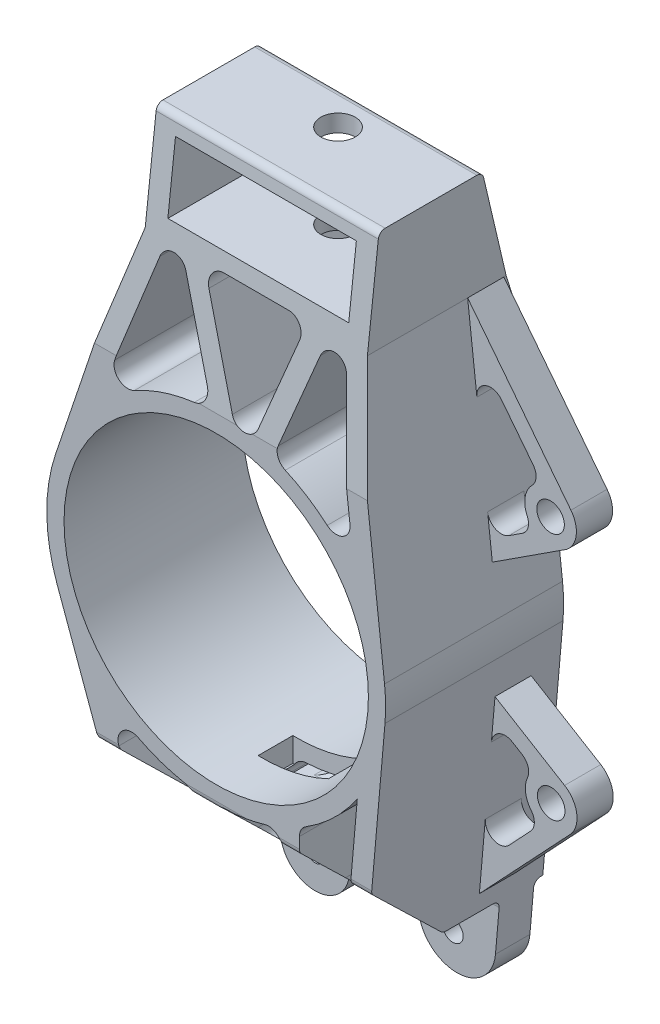
from build123d import *

# Parameters (mm, degrees)
SKETCH1_R               = 3
SKETCH1_R_2             = 44.17744667
SKETCH1_W               = 52.5
SKETCH1_H               = 19.5
BOSS_EXTRUDE1_DEPTH     = 25.835
CUT_EXTRUDE1_DEPTH      = 125.461402053
CUT_EXTRUDE1_DEPTH_BACK = 125.461402053
FILLET1_R               = 2
SKETCH5_R               = 4
BOSS_EXTRUDE2_DEPTH     = 10.5
BOSS_EXTRUDE3_DEPTH     = 26.37
CUT_EXTRUDE2_REACH      = 175.948
CUT_EXTRUDE2_END_RADIUS = 49.17744667
SKETCH7_R               = 2.75
CUT_EXTRUDE4_REACH      = 222.707
SKETCH10_R              = 5
CUT_EXTRUDE5_START      = -32.848332
CUT_EXTRUDE5_DEPTH      = 61.004944
SKETCH12_W              = 20.384350052
SKETCH12_H              = 10.085001151
CUT_EXTRUDE6_DEPTH      = 51.17744667


with BuildPart() as part:
    # Sketch1 → Boss-Extrude1 (new, symmetric)
    with BuildSketch(Plane.XY):
        with BuildLine():
            Line((-24.333061453, 81.876712624), (-46.608830439, 15.685604423))
            ThreePointArc((-46.608830439, 15.685604423), (-49.173776541, -0.600800907), (-46.211683745, -16.819677359))
            Line((-46.211683745, -16.819677359), (-19.916030232, -89.066391616))
            ThreePointArc((-19.916030232, -89.066391616), (-8.753130377, -95.528899343), (-0.427073715, -85.67744667))
            Line((-0.427073715, -85.67744667), (-0.427073715, -71.17744667))
            Line((-0.427073715, -71.17744667), (19.572926285, -71.17744667))
            Line((19.572926285, -71.17744667), (19.572926285, -85.67744667))
            ThreePointArc((19.572926285, -85.67744667), (30.838296467, -95.676822157), (41.890099306, -85.441895218))
            Line((41.890099306, -85.441895218), (48.990311639, -4.286096891))
            ThreePointArc((48.990311639, -4.286096891), (49.173233519, 0.643712888), (48.861326946, 5.567045008))
            Line((48.861326946, 5.567045008), (40.166938547, 81.876712624))
            Line((40.166938547, 81.876712624), (40.166938547, 111.376712624))
            Line((40.166938547, 111.376712624), (-24.333061453, 111.376712624))
            Line((-24.333061453, 111.376712624), (-24.333061453, 81.876712624))
        make_face()
        with Locations((-10.474465133, -85.629942955)):
            Circle(SKETCH1_R, mode=Mode.SUBTRACT)
        with Locations((29.525534867, -85.629942955)):
            Circle(SKETCH1_R, mode=Mode.SUBTRACT)
        Circle(SKETCH1_R_2, mode=Mode.SUBTRACT)
        with BuildLine():
            Line((-1.489783191, 81.876712624), (17.323660285, 81.876712624))
            ThreePointArc((17.323660285, 81.876712624), (20.595092, 80.178393429), (21.088556078, 76.525579889))
            Line((21.088556078, 76.525579889), (11.974377491, 51.129161219))
            ThreePointArc((11.974377491, 51.129161219), (8.249997752, 48.480499153), (4.472728318, 51.053173015))
            Line((4.472728318, 51.053173015), (-5.226536572, 76.449591685))
            ThreePointArc((-5.226536572, 76.449591685), (-4.784360839, 80.145138977), (-1.489783191, 81.876712624))
        make_face(mode=Mode.SUBTRACT)
        with Locations((7.916938547, 96.626712624)):
            Rectangle(SKETCH1_W, SKETCH1_H, mode=Mode.SUBTRACT)
        with BuildLine():
            Line((34.927451287, 74.861073276), (38.829349223, 40.614554616))
            ThreePointArc((38.829349223, 40.614554616), (36.718951762, 36.62254493), (32.233268993, 37.140781239))
            ThreePointArc((32.233268993, 37.140781239), (26.426414079, 41.473677194), (20.045955076, 44.906357524))
            ThreePointArc((20.045955076, 44.906357524), (17.997201864, 46.989529636), (17.911559151, 49.91008799))
            Line((17.911559151, 49.91008799), (27.188268072, 75.759393156))
            ThreePointArc((27.188268072, 75.759393156), (31.414364326, 78.381583228), (34.927451287, 74.861073276))
        make_face(mode=Mode.SUBTRACT)
        with BuildLine():
            Line((-12.022760406, 77.427653422), (-3.135959437, 54.158578845))
            ThreePointArc((-3.135959437, 54.158578845), (-3.438154868, 50.681138006), (-6.355748333, 48.765005118))
            ThreePointArc((-6.355748333, 48.765005118), (-15.310652659, 46.733341162), (-23.731752898, 43.07232482))
            ThreePointArc((-23.731752898, 43.07232482), (-28.226410266, 43.50588442), (-29.453122193, 47.851583055))
            Line((-29.453122193, 47.851583055), (-19.550587426, 77.27636972))
            ThreePointArc((-19.550587426, 77.27636972), (-15.839883944, 79.999724981), (-12.022760406, 77.427653422))
        make_face(mode=Mode.SUBTRACT)
        with BuildLine():
            Line((-28.275211733, -48.556902797), (-22.819798581, -63.545527244))
            ThreePointArc((-22.819798581, -63.545527244), (-21.355333844, -65.454054848), (-19.061028098, -66.17744667))
            Line((-19.061028098, -66.17744667), (-10.227738023, -66.17744667))
            ThreePointArc((-10.227738023, -66.17744667), (-7.399310898, -65.005873795), (-6.227738023, -62.17744667))
            Line((-6.227738023, -62.17744667), (-6.227738023, -52.184616596))
            ThreePointArc((-6.227738023, -52.184616596), (-7.139266231, -49.642699605), (-9.458409019, -48.259297134))
            ThreePointArc((-9.458409019, -48.259297134), (-16.230589371, -46.421861549), (-22.672318014, -43.639285705))
            ThreePointArc((-22.672318014, -43.639285705), (-27.155040875, -44.182530153), (-28.275211733, -48.556902797))
        make_face(mode=Mode.SUBTRACT)
        with BuildLine():
            Line((24.156612029, -45.111484496), (24.156612029, -62.17744667))
            ThreePointArc((24.156612029, -62.17744667), (25.328184905, -65.005873795), (28.156612029, -66.17744667))
            Line((28.156612029, -66.17744667), (37.552601137, -66.17744667))
            Line((37.552601137, -66.17744667), (40.961501413, -27.213538231))
            ThreePointArc((40.961501413, -27.213538231), (34.276118097, -35.264273553), (26.038675664, -41.718205027))
            ThreePointArc((26.038675664, -41.718205027), (24.658630793, -43.171348606), (24.156612029, -45.111484496))
        make_face(mode=Mode.SUBTRACT)
        with BuildLine():
            Line((-1.227738023, -53.105135325), (-1.227738023, -62.17744667))
            ThreePointArc((-1.227738023, -62.17744667), (-0.056165148, -65.005873795), (2.772261977, -66.17744667))
            Line((2.772261977, -66.17744667), (15.156612029, -66.17744667))
            ThreePointArc((15.156612029, -66.17744667), (17.985039154, -65.005873795), (19.156612029, -62.17744667))
            Line((19.156612029, -62.17744667), (19.156612029, -50.971736739))
            ThreePointArc((19.156612029, -50.971736739), (17.548231477, -47.765468438), (14.016533821, -47.137649927))
            ThreePointArc((14.016533821, -47.137649927), (8.348617755, -48.463613594), (2.563732824, -49.110574574))
            ThreePointArc((2.563732824, -49.110574574), (-0.128954717, -50.351421162), (-1.227738023, -53.105135325))
        make_face(mode=Mode.SUBTRACT)
    extrude(amount=BOSS_EXTRUDE1_DEPTH, both=True)

    # Sketch3 → Cut-Extrude1 (cut, two sides)
    with BuildSketch(Plane(origin=(0, 0, 0), x_dir=(0, 0, -1), z_dir=(1, 0, 0))) as cut_extrude1_sk:
        with BuildLine():
            Line((25.835, -95.67744667), (25.835, -71.17744667))
            Line((25.835, -71.17744667), (25.335, -71.17744667))
            ThreePointArc((25.335, -71.17744667), (23.920786438, -71.763233108), (23.335, -73.17744667))
            Line((23.335, -73.17744667), (23.335, -95.67744667))
            Line((23.335, -95.67744667), (25.835, -95.67744667))
        make_face()
        with BuildLine():
            Line((13.335, -95.67744667), (13.335, -73.17744667))
            ThreePointArc((13.335, -73.17744667), (12.749213562, -71.763233108), (11.335, -71.17744667))
            Line((11.335, -71.17744667), (-2.354089758, -71.17744667))
            ThreePointArc((-2.354089758, -71.17744667), (-3.105579113, -71.030893122), (-3.746935037, -70.612710419))
            Line((-3.746935037, -70.612710419), (-25.835, -49.17744667))
            Line((-25.835, -49.17744667), (-25.835, -95.67744667))
            Line((-25.835, -95.67744667), (13.335, -95.67744667))
        make_face()
        with BuildLine():
            Line((-25.835, 49.17744667), (-18.95036426, 109.603119051))
            ThreePointArc((-18.95036426, 109.603119051), (-18.294983881, 110.868827374), (-16.963220549, 111.376712624))
            Line((-16.963220549, 111.376712624), (-25.835, 111.376712624))
            Line((-25.835, 111.376712624), (-25.835, 49.17744667))
        make_face()
        with BuildLine():
            Line((11.613591816, 109.833253612), (25.835, 49.17744667))
            Line((25.835, 49.17744667), (25.835, 111.376712624))
            Line((25.835, 111.376712624), (9.666396313, 111.376712624))
            ThreePointArc((9.666396313, 111.376712624), (10.908756571, 110.944048258), (11.613591816, 109.833253612))
        make_face()
    extrude(amount=CUT_EXTRUDE1_DEPTH, mode=Mode.SUBTRACT)
    extrude(cut_extrude1_sk.sketch, amount=-CUT_EXTRUDE1_DEPTH_BACK, mode=Mode.SUBTRACT)

    # Fillet1
    fillet1_edges = [part.edges().sort_by_distance(p)[0] for p in [
        (-31.241885551, -49.17744667, 25.835),
        (-2.787508752, -49.17744667, 25.835),
        (21.444104907, -49.17744667, 25.835),
        (42.05136793, -49.17744667, 25.835),
    ]]
    fillet(fillet1_edges, radius=FILLET1_R)

    # Sketch5 → Boss-Extrude2 (add)
    with BuildSketch(Plane.XY.offset(-6.985)):
        with BuildLine():
            Line((40.166938547, 81.876712624), (70.147675928, 43.503118685))
            ThreePointArc((70.147675928, 43.503118685), (71.694607282, 38.083802311), (69.030880587, 33.117259582))
            Line((69.030880587, 33.117259582), (47.32817385, 19.023357034))
            Line((47.32817385, 19.023357034), (45.963969857, 30.996821812))
            ThreePointArc((45.963969857, 30.996821812), (48.23198232, 27.831814086), (52.116813419, 28.094952396))
            Line((52.116813419, 28.094952396), (56.014564965, 30.626181846))
            ThreePointArc((56.014564965, 30.626181846), (57.683412554, 32.886567746), (57.453951939, 35.686879249))
            ThreePointArc((57.453951939, 35.686879249), (56.843274314, 40.140256162), (58.888701598, 44.142970281))
            ThreePointArc((58.888701598, 44.142970281), (60.029514526, 46.719915118), (59.188001317, 49.409516268))
            Line((59.188001317, 49.409516268), (49.982109578, 61.192520367))
            ThreePointArc((49.982109578, 61.192520367), (45.315472094, 62.432036481), (42.855779141, 58.27706161))
            Line((42.855779141, 58.27706161), (40.166938547, 81.876712624))
        make_face()
        with Locations((64.237595276, 38.88565762)):
            Circle(SKETCH5_R, mode=Mode.SUBTRACT)
        with BuildLine():
            Line((48.107618786, -14.37532237), (68.306121721, -26.60797056))
            ThreePointArc((68.306121721, -26.60797056), (71.851527954, -32.005335718), (69.888183856, -38.157305806))
            Line((69.888183856, -38.157305806), (43.575520163, -66.17744667))
            Line((43.575520163, -66.17744667), (45.286961109, -46.615587136))
            ThreePointArc((45.286961109, -46.615587136), (47.63841806, -50.615546816), (52.187614411, -49.702398531))
            Line((52.187614411, -49.702398531), (58.438302844, -43.046091423))
            ThreePointArc((58.438302844, -43.046091423), (59.520118213, -40.443828112), (58.617555575, -37.774094134))
            ThreePointArc((58.617555575, -37.774094134), (56.990310347, -34.041069305), (57.55372767, -30.007961034))
            ThreePointArc((57.55372767, -30.007961034), (57.705097835, -27.19385622), (55.963333585, -24.978375205))
            Line((55.963333585, -24.978375205), (53.11874132, -23.255628894))
            ThreePointArc((53.11874132, -23.255628894), (49.236894445, -23.109895816), (47.06185449, -26.328462964))
            Line((47.06185449, -26.328462964), (48.107618786, -14.37532237))
        make_face()
        with Locations((64.420919151, -33.023202511)):
            Circle(SKETCH5_R, mode=Mode.SUBTRACT)
    extrude(amount=-BOSS_EXTRUDE2_DEPTH)

    # Sketch6 → Boss-Extrude3 (add)
    with BuildSketch(Plane.XY.offset(0.535)):
        with BuildLine():
            Line((-59.173776541, 10.685604423), (-59.173776541, -11.819677359))
            Line((-59.173776541, -11.819677359), (-54.412210142, -11.819677359))
            ThreePointArc((-54.412210142, -11.819677359), (-49.609902541, -13.168250627), (-46.211683745, -16.819677359))
            ThreePointArc((-46.211683745, -16.819677359), (-49.173776541, -0.600800907), (-46.608830439, 15.685604423))
            ThreePointArc((-46.608830439, 15.685604423), (-49.778293473, 12.042835646), (-54.412210142, 10.685604423))
            Line((-54.412210142, 10.685604423), (-59.173776541, 10.685604423))
        make_face()
    extrude(amount=-BOSS_EXTRUDE3_DEPTH)

    # Cut-Extrude2: up to this cylinder (the profile starts outside it)
    cut_extrude2_end = Plane(origin=(0, 0, -11.983796), z_dir=(0, 0, -1)) * Cylinder(CUT_EXTRUDE2_END_RADIUS, 461.248485341, mode=Mode.PRIVATE)
    # Sketch7 → Cut-Extrude2 (cut, up to the surface)
    with BuildSketch(Plane.ZY.offset(59.173776541), mode=Mode.PRIVATE) as cut_extrude2_sk1:
        with Locations((-16.982592212, -0.372740434)):
            Circle(SKETCH7_R)
    cut_extrude2_tool1 = extrude(cut_extrude2_sk1.sketch, amount=-CUT_EXTRUDE2_REACH, mode=Mode.PRIVATE) - cut_extrude2_end
    add(cut_extrude2_tool1.solids().sort_by_distance((-59.173777, -0.37274, -16.982592))[0], mode=Mode.SUBTRACT)
    # Sketch7 → Cut-Extrude2 (cut, up to the surface)
    with BuildSketch(Plane.ZY.offset(59.173776541), mode=Mode.PRIVATE) as cut_extrude2_sk2:
        with Locations((-6.985, -0.153309453)):
            Circle(SKETCH7_R)
    cut_extrude2_tool2 = extrude(cut_extrude2_sk2.sketch, amount=-CUT_EXTRUDE2_REACH, mode=Mode.PRIVATE) - cut_extrude2_end
    add(cut_extrude2_tool2.solids().sort_by_distance((-59.173777, -0.153309, -6.985))[0], mode=Mode.SUBTRACT)

    # Cut-Extrude4: up to this face of the body (flat: up to its plane)
    cut_extrude4_end = Plane(part.part.faces().sort_by_distance((7.916938547, 81.876712624, 1.970542423))[0])
    # Sketch10 → Cut-Extrude4 (cut, up to the picked face)
    with BuildSketch(Plane(origin=(0, 111.376712624, 0), x_dir=(1, 0, 0), z_dir=(0, 1, 0)), mode=Mode.PRIVATE) as cut_extrude4_sk1:
        with Locations(Location((7.916938547, 1.613591816, 0), (0, 0, 180))):
            Circle(SKETCH10_R)
    cut_extrude4_tool1 = split(extrude(cut_extrude4_sk1.sketch, amount=-CUT_EXTRUDE4_REACH, mode=Mode.PRIVATE), bisect_by=cut_extrude4_end, keep=Keep.BOTH, mode=Mode.PRIVATE)
    add(cut_extrude4_tool1.solids().sort_by(Axis((7.916939, 111.376713, -1.613592), (0, -1, 0)))[0], mode=Mode.SUBTRACT)

    # Sketch11 → Cut-Extrude5 (cut)
    with BuildSketch(Plane(origin=(0, 0, 0), x_dir=(0, 0, -1), z_dir=(1, 0, 0)).offset(CUT_EXTRUDE5_START)):
        with BuildLine():
            Line((12.835, -66.17744667), (0.078640968, -66.17744667))
            ThreePointArc((0.078640968, -66.17744667), (-1.048593065, -65.957616348), (-2.01062695, -65.330342294))
            Line((-2.01062695, -65.330342294), (-8.855175283, -58.68808101))
            ThreePointArc((-8.855175283, -58.68808101), (-9.546077042, -55.407951353), (-6.765907364, -53.535185386))
            Line((-6.765907364, -53.535185386), (12.835, -53.535185386))
            ThreePointArc((12.835, -53.535185386), (14.956320344, -54.413865043), (15.835, -56.535185386))
            Line((15.835, -56.535185386), (15.835, -63.17744667))
            ThreePointArc((15.835, -63.17744667), (14.956320344, -65.298767014), (12.835, -66.17744667))
        make_face()
    extrude(amount=CUT_EXTRUDE5_DEPTH, mode=Mode.SUBTRACT)

    # Sketch12 → Cut-Extrude6 (cut)
    with BuildSketch(Plane(origin=(0, 0, 0), x_dir=(1, 0, 0), z_dir=(0, 1, 0))):
        with Locations((8.964437003, -7.396590334)):
            Rectangle(SKETCH12_W, SKETCH12_H)
    extrude(amount=-CUT_EXTRUDE6_DEPTH, mode=Mode.SUBTRACT)


solid = part.part
